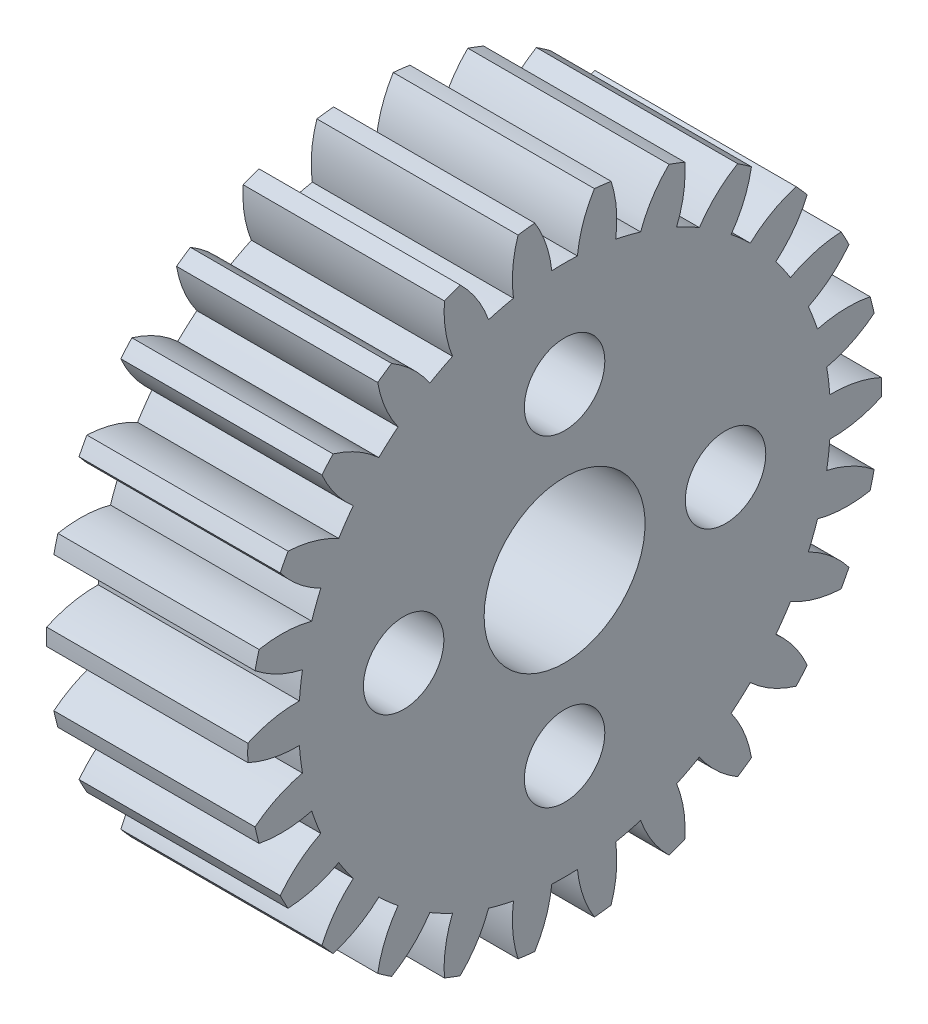
from build123d import *

# Parameters (mm, degrees)
BASPROSKE_W        = 10
BASPROSKE_H        = 15.75
TOOTHCUT_DEPTH     = 25.415671197
TEETHCUTS_COUNT    = 26
TEETHCUTS_ANGLE    = 346.153846154
BORSKE_R           = 4
BORE_DEPTH         = 50.0000508
SKETCH1_R          = 2
CUT_EXTRUDE2_DEPTH = 5
SKETCH2_R          = 1
CUT_EXTRUDE3_DEPTH = 10


with BuildPart() as part:
    # BasProSke → Base-Revolve (revolve)
    with BuildSketch(Plane(origin=(0, 0, 0), x_dir=(1, 0, 0), z_dir=(0, 1, 0)), mode=Mode.PRIVATE) as base_revolve_sk:
        with Locations((5, 7.875)):
            Rectangle(BASPROSKE_W, BASPROSKE_H)
    revolve(base_revolve_sk.sketch.rotate(Axis((-10, 0, 0), (1, 0, 0)), 180), axis=Axis((-10, 0, 0), (1, 0, 0)))

    # TooCutSke → ToothCut (cut, through all)
    with BuildSketch(Plane(origin=(0, 0, 0), x_dir=(0, 0, -1), z_dir=(1, 0, 0))):
        with BuildLine():
            ThreePointArc((0.637727704, 13.202356549), (0, 13.21775), (-0.637727704, 13.202356549))
            ThreePointArc((-0.637727704, 13.202356549), (-0.924330219, 14.50249659), (-1.497477225, 15.704165279))
            ThreePointArc((-1.497477225, 15.704165279), (0, 15.7754), (1.497477225, 15.704165279))
            ThreePointArc((1.497477225, 15.704165279), (0.924330219, 14.50249659), (0.637727704, 13.202356549))
        make_face()
    toothcut = extrude(amount=TOOTHCUT_DEPTH, mode=Mode.SUBTRACT)

    # TeethCuts: ToothCut ×26 about axis
    teethcuts_axis = Axis((-10, 0, 0), (1, 0, 0))
    for i in range(1, TEETHCUTS_COUNT):
        add(toothcut.rotate(teethcuts_axis, i * TEETHCUTS_ANGLE / (TEETHCUTS_COUNT - 1)), mode=Mode.SUBTRACT)

    # BorSke → Bore (cut, symmetric)
    with BuildSketch(Plane(origin=(0, 0, 0), x_dir=(0, 0, -1), z_dir=(1, 0, 0))):
        with Locations(Location((0, 0, 0), (0, 0, 180))):
            Circle(BORSKE_R)
    extrude(amount=BORE_DEPTH, both=True, mode=Mode.SUBTRACT)

    # Sketch1 → Cut-Extrude2 (cut)
    with BuildSketch(Plane(origin=(10, 0, 0), x_dir=(0, 0, -1), z_dir=(1, 0, 0))):
        with Locations((8, 0)):
            Circle(SKETCH1_R)
        with Locations((0, -8)):
            Circle(SKETCH1_R)
        with Locations((-8, 0)):
            Circle(SKETCH1_R)
        with Locations((0, 8)):
            Circle(SKETCH1_R)
    extrude(amount=-CUT_EXTRUDE2_DEPTH, mode=Mode.SUBTRACT)

    # Sketch2 → Cut-Extrude3 (cut)
    with BuildSketch(Plane(origin=(10, 0, 0), x_dir=(0, 0, -1), z_dir=(1, 0, 0))):
        with Locations((8, 0)):
            Circle(SKETCH2_R)
        with Locations((0, -8)):
            Circle(SKETCH2_R)
        with Locations((-8, 0)):
            Circle(SKETCH2_R)
        with Locations((0, 8)):
            Circle(SKETCH2_R)
    extrude(amount=-CUT_EXTRUDE3_DEPTH, mode=Mode.SUBTRACT)


solid = part.part
